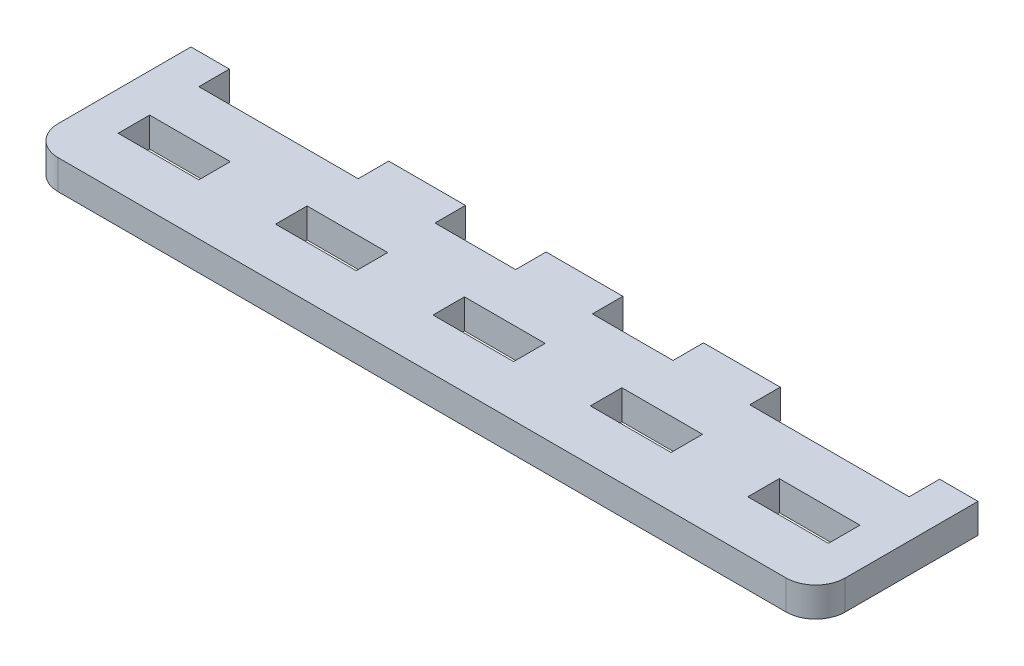
from build123d import *

# Parameters (mm, degrees)
SKETCH1_W           = 80
SKETCH1_H           = 16.5
BOSS_EXTRUDE1_DEPTH = 3
SKETCH3_W           = 8.2
SKETCH3_H           = 3.2
SKETCH3_W_2         = 16.2
CUT_EXTRUDE1_DEPTH  = 4
FILLET1_R           = 3


with BuildPart() as part:
    # Sketch1 → Boss-Extrude1 (new body)
    with BuildSketch(Plane(origin=(0, 0, 0), x_dir=(1, 0, 0), z_dir=(0, 1, 0))):
        with Locations((40, -8.25)):
            Rectangle(SKETCH1_W, SKETCH1_H)
    extrude(amount=-BOSS_EXTRUDE1_DEPTH)

    # Sketch3 → Cut-Extrude1 (cut, through all)
    with BuildSketch(Plane(origin=(0, 0, 0), x_dir=(1, 0, 0), z_dir=(0, 1, 0))):
        with Locations((8, -9.7)):
            Rectangle(SKETCH3_W, SKETCH3_H)
        with Locations((32, -1.5)):
            Rectangle(SKETCH3_W, SKETCH3_H)
        with Locations((40, -9.7)):
            Rectangle(SKETCH3_W, SKETCH3_H)
        with Locations((24, -9.7)):
            Rectangle(SKETCH3_W, SKETCH3_H)
        with Locations((12, -1.5)):
            Rectangle(SKETCH3_W_2, SKETCH3_H)
        with Locations((48, -1.5)):
            Rectangle(SKETCH3_W, SKETCH3_H)
        with Locations((56, -9.7)):
            Rectangle(SKETCH3_W, SKETCH3_H)
        with Locations((72, -9.7)):
            Rectangle(SKETCH3_W, SKETCH3_H)
        with Locations((68, -1.5)):
            Rectangle(SKETCH3_W_2, SKETCH3_H)
    extrude(amount=-CUT_EXTRUDE1_DEPTH, mode=Mode.SUBTRACT)

    # Fillet1
    fillet1_edges = [part.edges().sort_by_distance(p)[0] for p in [
        (80, -1.5, 16.5),
        (0, -1.5, 16.5),
    ]]
    fillet(fillet1_edges, radius=FILLET1_R)


solid = part.part
